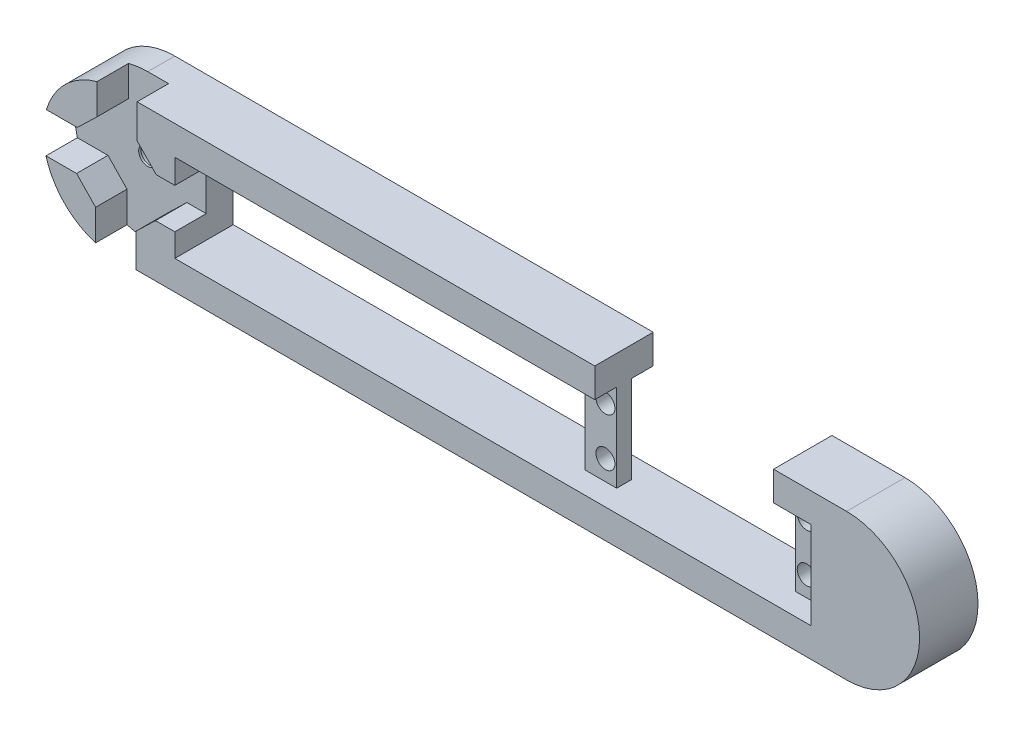
from build123d import *

# Parameters (mm, degrees)
BOSS_EXTRU_1_DEPTH       = 8
ESQUISSE4_W              = 82
ESQUISSE4_H              = 12
ENL_V_MAT_EXTRU_3_DEPTH  = 9
BOSS_EXTRU_2_REACH       = 18
ESQUISSE6_W              = 4.318
ESQUISSE6_H              = 8
ESQUISSE7_R              = 1.3
ENL_V_MAT_EXTRU_5_DEPTH  = 10
ESQUISSE8_W              = 5.09860661
ESQUISSE8_H              = 12
ESQUISSE8_W_2            = 4.318
ENL_V_MAT_EXTRU_6_DEPTH  = 3
ESQUISSE13_R             = 4
ENL_V_MAT_EXTRU_9_DEPTH  = 4.3
ENL_V_MAT_EXTRU_10_DEPTH = 4.3
ESQUISSE15_R             = 2.5
ENL_V_MAT_EXTRU_11_DEPTH = 3.4
ENL_V_MAT_EXTRU_12_REACH = 6.6
ESQUISSE16_R             = 1.25
ESQUISSE17_W             = 24.484825334
ESQUISSE17_H             = 8
ENL_V_MAT_EXTRU_13_DEPTH = 4.3
ESQUISSE18_W             = 4.318
ESQUISSE18_H             = 12
ENL_V_MAT_EXTRU_14_DEPTH = 3


with BuildPart() as part:
    # Esquisse1 → Boss.-Extru.1 (new body)
    with BuildSketch(Plane.XY):
        with BuildLine():
            Line((0, 0), (100, 0))
            ThreePointArc((100, 0), (110, 10), (100, 20))
            Line((100, 20), (0, 20))
            ThreePointArc((0, 20), (-10, 10), (0, 0))
        make_face()
    extrude(amount=BOSS_EXTRU_1_DEPTH)

    # Esquisse4 → Enlèv. mat.-Extru.3 (cut, through all)
    with BuildSketch(Plane.XY.offset(8)):
        with Locations((49, 10)):
            Rectangle(ESQUISSE4_W, ESQUISSE4_H)
    extrude(amount=-ENL_V_MAT_EXTRU_3_DEPTH, mode=Mode.SUBTRACT)

    # Esquisse6 → Boss.-Extru.2 (add, up to next)
    with BuildSketch(Plane(origin=(0, 4, 0), x_dir=(1, 0, 0), z_dir=(0, 1, 0)), mode=Mode.PRIVATE) as boss_extru_2_sk1:
        with Locations((63.356174666, -4)):
            Rectangle(ESQUISSE6_W, ESQUISSE6_H)
    boss_extru_2_tool1 = extrude(boss_extru_2_sk1.sketch, amount=BOSS_EXTRU_2_REACH, mode=Mode.PRIVATE) - part.part
    add(boss_extru_2_tool1.solids().sort_by_distance((63.356175, 4, 4))[0])

    # Esquisse7 → Enlèv. mat.-Extru.5 (cut)
    with BuildSketch(Plane(origin=(0, 0, 0), x_dir=(-1, 0, 0), z_dir=(0, 0, -1))):
        with Locations((-91.542174666, 13.344)):
            Circle(ESQUISSE7_R)
        with Locations((-91.542174666, 6.74)):
            Circle(ESQUISSE7_R)
        with Locations((-63.973, 6.74)):
            Circle(ESQUISSE7_R)
        with Locations((-63.973, 13.344)):
            Circle(ESQUISSE7_R)
    extrude(amount=-ENL_V_MAT_EXTRU_5_DEPTH, mode=Mode.SUBTRACT)

    # Esquisse8 → Enlèv. mat.-Extru.6 (cut)
    with BuildSketch(Plane.XY.offset(8)):
        with Locations((92.549303305, 10)):
            Rectangle(ESQUISSE8_W, ESQUISSE8_H)
        with Locations((63.356174666, 10)):
            Rectangle(ESQUISSE8_W_2, ESQUISSE8_H)
    extrude(amount=-ENL_V_MAT_EXTRU_6_DEPTH, mode=Mode.SUBTRACT)

    # Esquisse13 → Enlèv. mat.-Extru.9 (cut)
    with BuildSketch(Plane.XY.offset(8)):
        with Locations((0, 10)):
            Circle(ESQUISSE13_R)
    extrude(amount=-ENL_V_MAT_EXTRU_9_DEPTH, mode=Mode.SUBTRACT)

    # Esquisse14 → Enlèv. mat.-Extru.10 (cut)
    with BuildSketch(Plane.XY.offset(8)):
        Polygon((2.655377087, 4.544050257), (2.655377087, -2.008601379), (-2.844622913, -1.912365766), (-2.844622913, 4.640285869), (-5.455949743, 7.344622913), (-12.008601379, 7.344622913), (-11.912365766, 12.844622913), (-5.359714131, 12.844622913), (-2.655377087, 15.455949743), (-2.655377087, 22.008601379), (2.844622913, 21.912365766), (2.844622913, 15.359714131), (5.455949743, 12.655377087), (12.008601379, 12.655377087), (11.912365766, 7.155377087), (5.359714131, 7.155377087), align=None)
    extrude(amount=-ENL_V_MAT_EXTRU_10_DEPTH, mode=Mode.SUBTRACT)

    # Esquisse15 → Enlèv. mat.-Extru.11 (cut)
    with BuildSketch(Plane(origin=(0, 0, 0), x_dir=(-1, 0, 0), z_dir=(0, 0, -1))):
        with Locations((0, 10)):
            Circle(ESQUISSE15_R)
    extrude(amount=-ENL_V_MAT_EXTRU_11_DEPTH, mode=Mode.SUBTRACT)

    # Esquisse16 → Enlèv. mat.-Extru.12 (cut, up to next)
    with BuildSketch(Plane(origin=(0, 0, 3.4), x_dir=(-1, 0, 0), z_dir=(0, 0, -1)), mode=Mode.PRIVATE) as enl_v_mat_extru_12_sk1:
        with Locations((0, 10)):
            Circle(ESQUISSE16_R)
    enl_v_mat_extru_12_tool1 = extrude(enl_v_mat_extru_12_sk1.sketch, amount=-ENL_V_MAT_EXTRU_12_REACH, mode=Mode.PRIVATE) & part.part
    add(enl_v_mat_extru_12_tool1.solids().sort_by_distance((0, 10, 3.4))[0], mode=Mode.SUBTRACT)

    # Esquisse17 → Enlèv. mat.-Extru.13 (cut)
    with BuildSketch(Plane(origin=(0, 20, 0), x_dir=(1, 0, 0), z_dir=(0, 1, 0))):
        with Locations((77.757587333, -4)):
            Rectangle(ESQUISSE17_W, ESQUISSE17_H)
    extrude(amount=-ENL_V_MAT_EXTRU_13_DEPTH, mode=Mode.SUBTRACT)

    # Esquisse18 → Enlèv. mat.-Extru.14 (cut)
    with BuildSketch(Plane(origin=(0, 0, 0), x_dir=(-1, 0, 0), z_dir=(0, 0, -1))):
        with Locations((-63.356174666, 10)):
            Rectangle(ESQUISSE18_W, ESQUISSE18_H)
        with Locations((-92.159, 10)):
            Rectangle(ESQUISSE18_W, ESQUISSE18_H)
    extrude(amount=-ENL_V_MAT_EXTRU_14_DEPTH, mode=Mode.SUBTRACT)


solid = part.part
